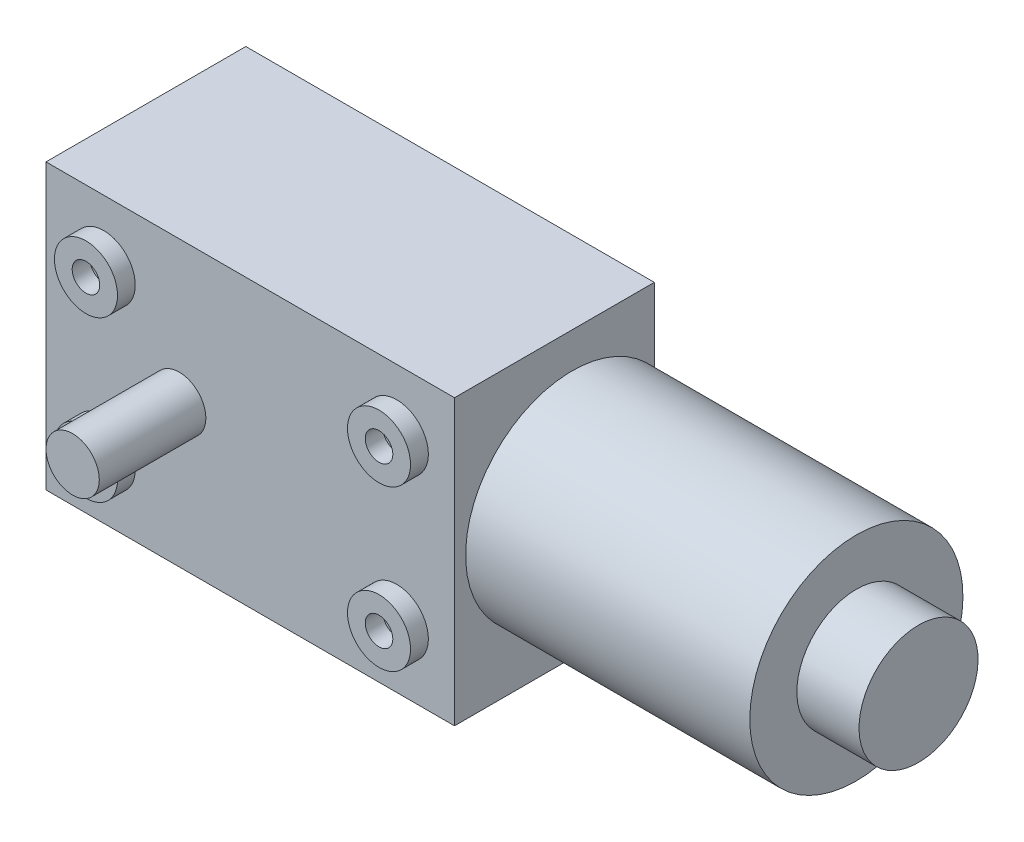
from build123d import *

# Parameters (mm, degrees)
SKETCH2_W           = 46
SKETCH2_H           = 32
BOSS_EXTRUDE1_DEPTH = 22.5
SKETCH3_R           = 3
BOSS_EXTRUDE2_DEPTH = 12
SKETCH4_R           = 3.55
SKETCH4_R_2         = 1.55
BOSS_EXTRUDE3_DEPTH = 2
SKETCH5_R           = 12
BOSS_EXTRUDE4_DEPTH = 32
SKETCH6_R           = 6.7
BOSS_EXTRUDE5_DEPTH = 7


with BuildPart() as part:
    # Sketch2 → Boss-Extrude1 (new body)
    with BuildSketch(Plane.XY):
        Rectangle(SKETCH2_W, SKETCH2_H)
    extrude(amount=BOSS_EXTRUDE1_DEPTH)

    # Sketch3 → Boss-Extrude2 (add)
    with BuildSketch(Plane.XY.offset(22.5)):
        with Locations((-8, 0)):
            Circle(SKETCH3_R)
    extrude(amount=BOSS_EXTRUDE2_DEPTH)

    # Sketch4 → Boss-Extrude3 (add)
    with BuildSketch(Plane.XY.offset(22.5)):
        with Locations((-16.5, 9)):
            Circle(SKETCH4_R)
        with Locations((-16.5, 9)):
            Circle(SKETCH4_R_2, mode=Mode.SUBTRACT)
        with Locations((-16.5, -9)):
            Circle(SKETCH4_R)
        with Locations((-16.5, -9)):
            Circle(SKETCH4_R_2, mode=Mode.SUBTRACT)
        with Locations((16.5, -9)):
            Circle(SKETCH4_R)
        with Locations((16.5, -9)):
            Circle(SKETCH4_R_2, mode=Mode.SUBTRACT)
        with Locations((16.5, 9)):
            Circle(SKETCH4_R)
        with Locations((16.5, 9)):
            Circle(SKETCH4_R_2, mode=Mode.SUBTRACT)
    extrude(amount=BOSS_EXTRUDE3_DEPTH)

    # Sketch5 → Boss-Extrude4 (add)
    with BuildSketch(Plane(origin=(23, 0, 0), x_dir=(0, 0, -1), z_dir=(1, 0, 0))):
        with Locations((-9.25, 0)):
            Circle(SKETCH5_R)
    extrude(amount=BOSS_EXTRUDE4_DEPTH)

    # Sketch6 → Boss-Extrude5 (add)
    with BuildSketch(Plane(origin=(55, 0, 0), x_dir=(0, 0, -1), z_dir=(1, 0, 0))):
        with Locations((-9.25, 0)):
            Circle(SKETCH6_R)
    extrude(amount=BOSS_EXTRUDE5_DEPTH)


solid = part.part
